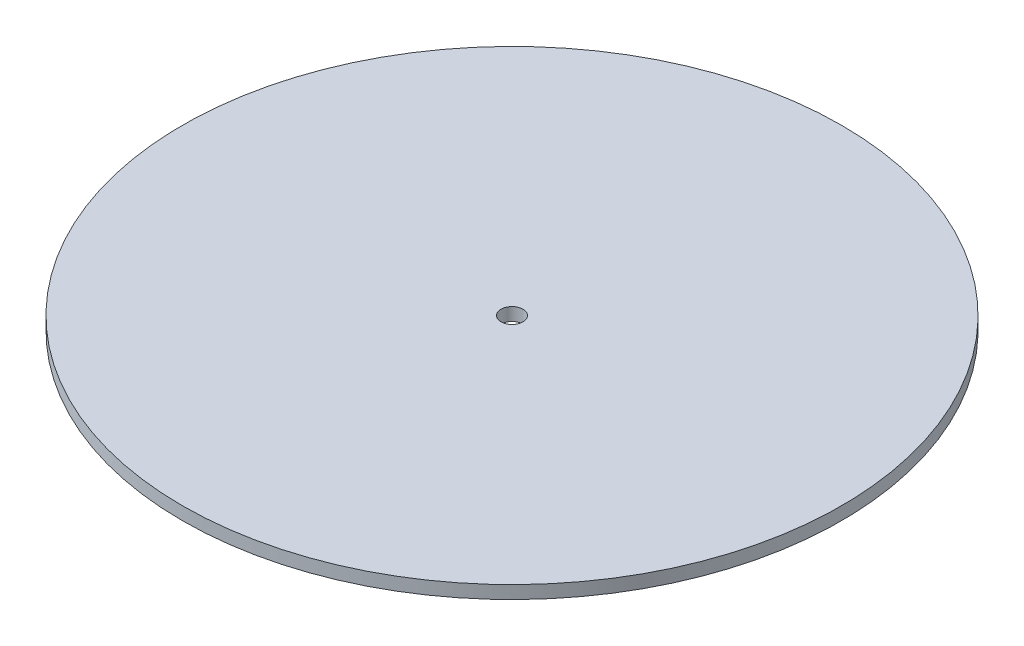
from build123d import *

# Parameters (mm, degrees)
SKETCH1_R           = 76.2
SKETCH1_R_2         = 2.54
BOSS_EXTRUDE1_DEPTH = 3


with BuildPart() as part:
    # Sketch1 → Boss-Extrude1 (new body)
    with BuildSketch(Plane(origin=(0, 0, 0), x_dir=(1, 0, 0), z_dir=(0, 1, 0))):
        Circle(SKETCH1_R)
        Circle(SKETCH1_R_2, mode=Mode.SUBTRACT)
    extrude(amount=BOSS_EXTRUDE1_DEPTH)


solid = part.part
